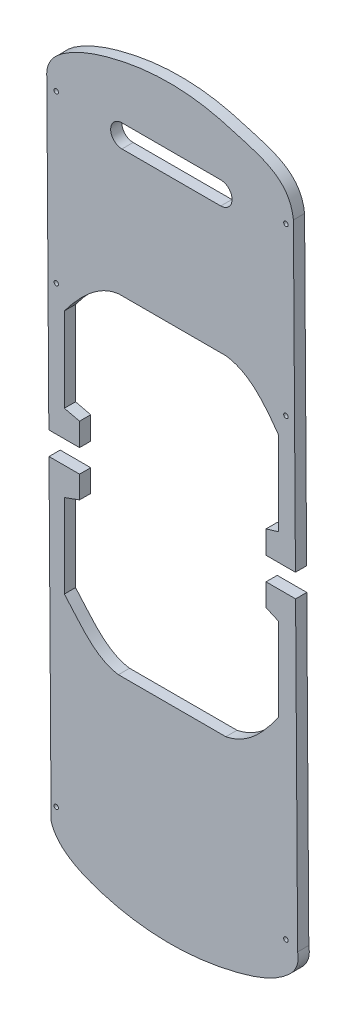
from build123d import *

# Parameters (mm, degrees)
OUTER_CUT_EXTRUDE_DEPTH   = 10
HANDLE_CUT_DEPTH          = 10
HOLES_R                   = 2
HOLES_CUT_DEPTH           = 10
WHEEL_HOLE_CUT_DEPTH      = 10
SKETCH7_W                 = 220.786532647
SKETCH7_H                 = 20.523195184
SEPERATE_FOR_CUTTER_DEPTH = 10


with BuildPart() as part:
    # Outer Cut → Outer Cut Extrude (new body)
    with BuildSketch(Plane.XY):
        with BuildLine():
            Line((-113.64875635, 299.149763984), (-109.816211971, -275.093135424))
            add(Edge.make_bspline(
                [(-109.816211971, -275.093135424), (-106.607178942, -285.722495836), (-92.230200108, -298.128562103), (-66.171478097, -308.125545605), (-35.490240898, -315.680442969), (7.349343337, -318.529337487), (55.259367963, -311.199249304), (97.276130628, -296.385821585), (112.870760282, -277.133248797), (110.774119471, -266.218850205)],
                knots=[0, 0, 0, 0, 0.122425719, 0.216064372, 0.327166115, 0.494333937, 0.717397449, 0.89956502, 1, 1, 1, 1], degree=3))
            Line((110.774119471, -266.218850205), (107.000802803, 299.149763984))
            add(Edge.make_bspline(
                [(-113.64875635, 299.149763984), (-114.92443064, 313.197885337), (-94.849800602, 330.39336024), (-61.010041387, 342.622533437), (-18.918767828, 351.176947948), (23.609481642, 349.753915079), (71.687448298, 335.692246865), (104.096362102, 325.361995633), (107.000802803, 299.149763984)],
                knots=[0, 0, 0, 0, 0.141861647, 0.27997283, 0.41653257, 0.634994384, 0.759518976, 1, 1, 1, 1], degree=3))
        make_face()
    extrude(amount=OUTER_CUT_EXTRUDE_DEPTH)

    # Handle → Handle Cut (cut)
    with BuildSketch(Plane.XY):
        with BuildLine():
            Line((-46.400999152, 297.666324186), (41.981712091, 297.666324186))
            ThreePointArc((41.981712091, 297.666324186), (52.096354794, 287.551681482), (41.981712091, 277.437038779))
            Line((41.981712091, 277.437038779), (-46.400999152, 277.437038779))
            ThreePointArc((-46.400999152, 277.437038779), (-56.515641856, 287.551681482), (-46.400999152, 297.666324186))
        make_face()
    extrude(amount=HANDLE_CUT_DEPTH, mode=Mode.SUBTRACT)

    # Holes → Holes Cut (cut)
    with BuildSketch(Plane.XY):
        with Locations((100.286043104, 292.77598768)):
            Circle(HOLES_R)
        with Locations((-105.2341902, 292.77598768)):
            Circle(HOLES_R)
        with Locations((-105.2341902, 144.013070247)):
            Circle(HOLES_R)
        with Locations((100.286043104, 144.013070247)):
            Circle(HOLES_R)
        with Locations((-105.2341902, -261.81330375)):
            Circle(HOLES_R)
        with Locations((100.2860431, -261.817262146)):
            Circle(HOLES_R)
    extrude(amount=HOLES_CUT_DEPTH, mode=Mode.SUBTRACT)

    # Wheel Hole → Wheel Hole Cut (cut)
    with BuildSketch(Plane.XY):
        with BuildLine():
            Line((-49.578885474, 163.660859039), (46.538823299, 163.660859039))
            add(Edge.make_bspline(
                [(46.538823299, 163.660859039), (68.37258014, 160.868866886), (81.804733275, 142.525461888), (93.454040823, 126.216230162)],
                knots=[0, 0, 0, 0, 1, 1, 1, 1], degree=3))
            Line((93.454040823, 126.216230162), (93.454040823, 50.747913124))
            Line((93.454040823, 50.747913124), (82.509254189, 47.494057639))
            Line((82.509254189, 47.494057639), (82.509254189, -13.537739036))
            Line((82.509254189, -13.537739036), (93.454040823, -18.433975269))
            Line((93.454040823, -18.433975269), (93.454040823, -93.251893693))
            add(Edge.make_bspline(
                [(93.454040823, -93.251893693), (81.898905096, -109.410102116), (67.308000888, -127.522433958), (46.538823299, -131.563109806)],
                knots=[0, 0, 0, 0, 1, 1, 1, 1], degree=3))
            Line((46.538823299, -131.563109806), (-49.578885474, -131.563109806))
            add(Edge.make_bspline(
                [(-49.578885474, -131.563109806), (-71.532579158, -128.371697231), (-84.306155821, -107.78849923), (-97.932579458, -93.251893693)],
                knots=[0, 0, 0, 0, 1, 1, 1, 1], degree=3))
            Line((-97.932579458, -93.251893693), (-97.932579458, -18.433975269))
            Line((-97.932579458, -18.433975269), (-84.369957975, -13.537739036))
            Line((-84.369957975, -13.537739036), (-84.369957975, 47.494057639))
            Line((-84.369957975, 47.494057639), (-97.932579458, 50.737293211))
            Line((-97.932579458, 50.737293211), (-97.932579458, 126.216230162))
            add(Edge.make_bspline(
                [(-49.578885474, 163.660859039), (-60.56164238, 162.119859802), (-78.227406764, 150.263949312), (-91.83300307, 134.413103774), (-97.932579458, 126.216230162)],
                knots=[0, 0, 0, 0, 0.510558335, 1, 1, 1, 1], degree=3))
        make_face()
    extrude(amount=WHEEL_HOLE_CUT_DEPTH, mode=Mode.SUBTRACT)

    # Sketch7 → Seperate For Cutter (cut)
    with BuildSketch(Plane.XY):
        with Locations((-1.439044765, 16.72411794)):
            Rectangle(SKETCH7_W, SKETCH7_H)
    extrude(amount=SEPERATE_FOR_CUTTER_DEPTH, mode=Mode.SUBTRACT)


solid = part.part
